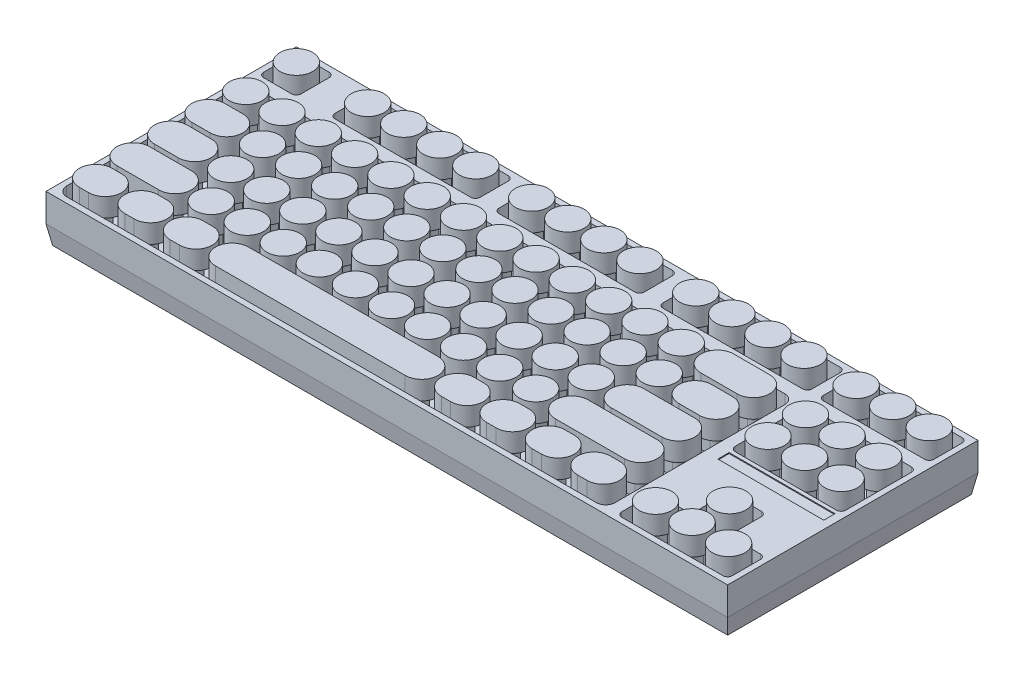
from build123d import *

# Parameters (mm, degrees)
SKETCH1_W            = 360
SKETCH1_H            = 130
BOSS_EXTRUDE1_DEPTH  = 10
DRAFT1_ANGLE         = 10
SKETCH2_W            = 363.526539614
SKETCH2_H            = 133.526539614
BOSS_EXTRUDE2_DEPTH  = 15
SKETCH3_R            = 4.5
BOSS_EXTRUDE3_DEPTH  = 15
BOSS_EXTRUDE5_START  = -4
SKETCH4_R            = 8.75
BOSS_EXTRUDE5_DEPTH  = 10
SKETCH5_W            = 56.5
SKETCH5_H            = 6
CUT_EXTRUDE1_DEPTH   = 0.5
SKETCH6_W            = 20
SKETCH6_H            = 20
CUT_EXTRUDE2_DEPTH   = 3
BOSS_EXTRUDE6_DEPTH  = 1
CUT_EXTRUDE3_DEPTH   = 20
CUT_EXTRUDE4_START   = -270
CUT_EXTRUDE4_DEPTH   = 20
BOSS_EXTRUDE7_DEPTH  = 20
BOSS_EXTRUDE8_START  = -290
BOSS_EXTRUDE8_DEPTH  = 20
BOSS_EXTRUDE12_DEPTH = 20
BOSS_EXTRUDE13_START = -290
BOSS_EXTRUDE13_DEPTH = 20


with BuildPart() as part:
    # Sketch1 → Boss-Extrude1 (new body)
    with BuildSketch(Plane(origin=(0, 0, 0), x_dir=(1, 0, 0), z_dir=(0, 1, 0))):
        Rectangle(SKETCH1_W, SKETCH1_H)
    extrude(amount=BOSS_EXTRUDE1_DEPTH)

    # Draft1
    draft1_faces = [part.faces().sort_by_distance(p)[0] for p in [
        (180, 5, 0),
        (0, 5, -65),
        (-180, 5, 0),
        (0, 5, 65),
    ]]
    draft(draft1_faces, Plane(origin=(0, 0, 0), x_dir=(0, 0, -1), z_dir=(0, -1, 0)), DRAFT1_ANGLE)

    # Sketch2 → Boss-Extrude2 (add)
    with BuildSketch(Plane(origin=(0, 10, 0), x_dir=(1, 0, 0), z_dir=(0, 1, 0))):
        Rectangle(SKETCH2_W, SKETCH2_H)
        with BuildLine():
            Line((111.263269807, 63.763269807), (36.766730193, 63.763269807))
            ThreePointArc((36.766730193, 63.763269807), (34.99896324, 63.03103676), (34.266730193, 61.263269807))
            Line((34.266730193, 61.263269807), (34.266730193, 46.263269807))
            ThreePointArc((34.266730193, 46.263269807), (34.99896324, 44.495502854), (36.766730193, 43.763269807))
            Line((36.766730193, 43.763269807), (111.263269807, 43.763269807))
            ThreePointArc((111.263269807, 43.763269807), (113.03103676, 44.495502854), (113.763269807, 46.263269807))
            Line((113.763269807, 46.263269807), (113.763269807, 61.263269807))
            ThreePointArc((113.763269807, 61.263269807), (113.03103676, 63.03103676), (111.263269807, 63.763269807))
        make_face(mode=Mode.SUBTRACT)
        with BuildLine():
            Line((176.263269807, 63.763269807), (122.263269807, 63.763269807))
            ThreePointArc((122.263269807, 63.763269807), (120.495502854, 63.03103676), (119.763269807, 61.263269807))
            Line((119.763269807, 61.263269807), (119.763269807, 46.263269807))
            ThreePointArc((119.763269807, 46.263269807), (120.495502854, 44.495502854), (122.263269807, 43.763269807))
            Line((122.263269807, 43.763269807), (176.263269807, 43.763269807))
            ThreePointArc((176.263269807, 43.763269807), (178.03103676, 44.495502854), (178.763269807, 46.263269807))
            Line((178.763269807, 46.263269807), (178.763269807, 61.263269807))
            ThreePointArc((178.763269807, 61.263269807), (178.03103676, 63.03103676), (176.263269807, 63.763269807))
        make_face(mode=Mode.SUBTRACT)
        with BuildLine():
            Line((178.763269807, -46.263269807), (178.763269807, -61.263269807))
            ThreePointArc((178.763269807, -61.263269807), (178.03103676, -63.03103676), (176.263269807, -63.763269807))
            Line((176.263269807, -63.763269807), (122.263269807, -63.763269807))
            ThreePointArc((122.263269807, -63.763269807), (120.495502854, -63.03103676), (119.763269807, -61.263269807))
            Line((119.763269807, -61.263269807), (119.763269807, -46.263269807))
            ThreePointArc((119.763269807, -46.263269807), (120.495502854, -44.495502854), (122.263269807, -43.763269807))
            Line((122.263269807, -43.763269807), (136.763269807, -43.763269807))
            ThreePointArc((136.763269807, -43.763269807), (138.53103676, -43.03103676), (139.263269807, -41.263269807))
            Line((139.263269807, -41.263269807), (139.263269807, -26.263269807))
            ThreePointArc((139.263269807, -26.263269807), (139.995502854, -24.495502854), (141.763269807, -23.763269807))
            Line((141.763269807, -23.763269807), (156.763269807, -23.763269807))
            ThreePointArc((156.763269807, -23.763269807), (158.53103676, -24.495502854), (159.263269807, -26.263269807))
            Line((159.263269807, -26.263269807), (159.263269807, -41.263269807))
            ThreePointArc((159.263269807, -41.263269807), (159.995502854, -43.03103676), (161.763269807, -43.763269807))
            Line((161.763269807, -43.763269807), (176.263269807, -43.763269807))
            ThreePointArc((176.263269807, -43.763269807), (178.03103676, -44.495502854), (178.763269807, -46.263269807))
        make_face(mode=Mode.SUBTRACT)
        with BuildLine():
            Line((-178.763269807, 31.763269807), (-178.763269807, -58.763269807))
            ThreePointArc((-178.763269807, -58.763269807), (-177.298803713, -62.298803713), (-173.763269807, -63.763269807))
            Line((-173.763269807, -63.763269807), (108.763269807, -63.763269807))
            ThreePointArc((108.763269807, -63.763269807), (112.298803713, -62.298803713), (113.763269807, -58.763269807))
            Line((113.763269807, -58.763269807), (113.763269807, 31.763269807))
            ThreePointArc((113.763269807, 31.763269807), (112.298803713, 35.298803713), (108.763269807, 36.763269807))
            Line((108.763269807, 36.763269807), (-173.763269807, 36.763269807))
            ThreePointArc((-173.763269807, 36.763269807), (-177.298803713, 35.298803713), (-178.763269807, 31.763269807))
        make_face(mode=Mode.SUBTRACT)
        with BuildLine():
            Line((-161.263269807, 63.763269807), (-176.263269807, 63.763269807))
            ThreePointArc((-176.263269807, 63.763269807), (-178.03103676, 63.03103676), (-178.763269807, 61.263269807))
            Line((-178.763269807, 61.263269807), (-178.763269807, 46.263269807))
            ThreePointArc((-178.763269807, 46.263269807), (-178.03103676, 44.495502854), (-176.263269807, 43.763269807))
            Line((-176.263269807, 43.763269807), (-161.263269807, 43.763269807))
            ThreePointArc((-161.263269807, 43.763269807), (-159.495502854, 44.495502854), (-158.763269807, 46.263269807))
            Line((-158.763269807, 46.263269807), (-158.763269807, 61.263269807))
            ThreePointArc((-158.763269807, 61.263269807), (-159.495502854, 63.03103676), (-161.263269807, 63.763269807))
        make_face(mode=Mode.SUBTRACT)
        with BuildLine():
            Line((-65.733269807, 63.763269807), (-138.233269807, 63.763269807))
            ThreePointArc((-138.233269807, 63.763269807), (-140.00103676, 63.03103676), (-140.733269807, 61.263269807))
            Line((-140.733269807, 61.263269807), (-140.733269807, 46.263269807))
            ThreePointArc((-140.733269807, 46.263269807), (-140.00103676, 44.495502854), (-138.233269807, 43.763269807))
            Line((-138.233269807, 43.763269807), (-65.733269807, 43.763269807))
            ThreePointArc((-65.733269807, 43.763269807), (-63.965502854, 44.495502854), (-63.233269807, 46.263269807))
            Line((-63.233269807, 46.263269807), (-63.233269807, 61.263269807))
            ThreePointArc((-63.233269807, 61.263269807), (-63.965502854, 63.03103676), (-65.733269807, 63.763269807))
        make_face(mode=Mode.SUBTRACT)
        with BuildLine():
            Line((21.766730193, 63.763269807), (-50.733269807, 63.763269807))
            ThreePointArc((-50.733269807, 63.763269807), (-52.50103676, 63.03103676), (-53.233269807, 61.263269807))
            Line((-53.233269807, 61.263269807), (-53.233269807, 46.263269807))
            ThreePointArc((-53.233269807, 46.263269807), (-52.50103676, 44.495502854), (-50.733269807, 43.763269807))
            Line((-50.733269807, 43.763269807), (21.766730193, 43.763269807))
            ThreePointArc((21.766730193, 43.763269807), (23.534497146, 44.495502854), (24.266730193, 46.263269807))
            Line((24.266730193, 46.263269807), (24.266730193, 61.263269807))
            ThreePointArc((24.266730193, 61.263269807), (23.534497146, 63.03103676), (21.766730193, 63.763269807))
        make_face(mode=Mode.SUBTRACT)
        with BuildLine():
            Line((176.263269807, 36.763269807), (122.263269807, 36.763269807))
            ThreePointArc((122.263269807, 36.763269807), (120.495502854, 36.03103676), (119.763269807, 34.263269807))
            Line((119.763269807, 34.263269807), (119.763269807, -0.736730193))
            ThreePointArc((119.763269807, -0.736730193), (120.495502854, -2.504497146), (122.263269807, -3.236730193))
            Line((122.263269807, -3.236730193), (176.263269807, -3.236730193))
            ThreePointArc((176.263269807, -3.236730193), (178.03103676, -2.504497146), (178.763269807, -0.736730193))
            Line((178.763269807, -0.736730193), (178.763269807, 34.263269807))
            ThreePointArc((178.763269807, 34.263269807), (178.03103676, 36.03103676), (176.263269807, 36.763269807))
        make_face(mode=Mode.SUBTRACT)
    extrude(amount=BOSS_EXTRUDE2_DEPTH)

    # Sketch3 → Boss-Extrude3 (add)
    with BuildSketch(Plane(origin=(0, 10, 0), x_dir=(1, 0, 0), z_dir=(0, 1, 0))):
        with Locations((-168.763269807, 53.763269807)):
            Circle(SKETCH3_R)
        with Locations((-130.733269807, 53.763269807)):
            Circle(SKETCH3_R)
        with Locations((-111.508269807, 53.763269807)):
            Circle(SKETCH3_R)
        with Locations((-92.458269807, 53.763269807)):
            Circle(SKETCH3_R)
        with Locations((-73.233269807, 53.763269807)):
            Circle(SKETCH3_R)
        with Locations((-43.233269807, 53.763269807)):
            Circle(SKETCH3_R)
        with Locations((44.266730193, 53.763269807)):
            Circle(SKETCH3_R)
        with Locations((129.763269807, 53.763269807)):
            Circle(SKETCH3_R)
        with Locations((-24.003269807, 53.763269807)):
            Circle(SKETCH3_R)
        with Locations((-4.773269807, 53.763269807)):
            Circle(SKETCH3_R)
        with Locations((14.456730193, 53.763269807)):
            Circle(SKETCH3_R)
        with Locations((63.496730193, 53.763269807)):
            Circle(SKETCH3_R)
        with Locations((82.726730193, 53.763269807)):
            Circle(SKETCH3_R)
        with Locations((101.956730193, 53.763269807)):
            Circle(SKETCH3_R)
        with Locations((168.763269807, 53.763269807)):
            Circle(SKETCH3_R)
        with Locations((149.263269807, 53.763269807)):
            Circle(SKETCH3_R)
        with Locations((129.763269807, 26.763269807)):
            Circle(SKETCH3_R)
        with Locations((149.263269807, 26.763269807)):
            Circle(SKETCH3_R)
        with Locations((168.763269807, 26.763269807)):
            Circle(SKETCH3_R)
        with Locations((168.763269807, 6.763269807)):
            Circle(SKETCH3_R)
        with Locations((149.263269807, 6.763269807)):
            Circle(SKETCH3_R)
        with Locations((129.763269807, 6.763269807)):
            Circle(SKETCH3_R)
        with Locations((63.496730193, 26.763269807)):
            Circle(SKETCH3_R)
        with Locations((44.141730193, 26.763269807)):
            Circle(SKETCH3_R)
        with Locations((24.786730193, 26.763269807)):
            Circle(SKETCH3_R)
        with Locations((5.431730193, 26.763269807)):
            Circle(SKETCH3_R)
        with Locations((-13.923269807, 26.763269807)):
            Circle(SKETCH3_R)
        with Locations((-33.278269807, 26.763269807)):
            Circle(SKETCH3_R)
        with Locations((-52.633269807, 26.763269807)):
            Circle(SKETCH3_R)
        with Locations((-71.988269807, 26.763269807)):
            Circle(SKETCH3_R)
        with Locations((-91.343269807, 26.763269807)):
            Circle(SKETCH3_R)
        with Locations((-110.698269807, 26.763269807)):
            Circle(SKETCH3_R)
        with Locations((-130.053269807, 26.763269807)):
            Circle(SKETCH3_R)
        with Locations((-149.408269807, 26.763269807)):
            Circle(SKETCH3_R)
        with Locations((-168.763269807, 26.763269807)):
            Circle(SKETCH3_R)
        with Locations((129.763269807, -53.236730193)):
            Circle(SKETCH3_R)
        with Locations((149.263269807, -53.236730193)):
            Circle(SKETCH3_R)
        with Locations((168.763269807, -53.236730193)):
            Circle(SKETCH3_R)
        with Locations((149.263269807, -33.236730193)):
            Circle(SKETCH3_R)
        with Locations((-139.793269807, 6.763269807)):
            Circle(SKETCH3_R)
        with Locations((-120.563269807, 6.763269807)):
            Circle(SKETCH3_R)
        with Locations((-101.333269807, 6.763269807)):
            Circle(SKETCH3_R)
        with Locations((-82.103269807, 6.763269807)):
            Circle(SKETCH3_R)
        with Locations((-62.873269807, 6.763269807)):
            Circle(SKETCH3_R)
        with Locations((-43.643269807, 6.763269807)):
            Circle(SKETCH3_R)
        with Locations((-24.413269807, 6.763269807)):
            Circle(SKETCH3_R)
        with Locations((-5.183269807, 6.763269807)):
            Circle(SKETCH3_R)
        with Locations((14.046730193, 6.763269807)):
            Circle(SKETCH3_R)
        with Locations((33.276730193, 6.763269807)):
            Circle(SKETCH3_R)
        with Locations((52.506730193, 6.763269807)):
            Circle(SKETCH3_R)
        with Locations((71.736730193, 6.763269807)):
            Circle(SKETCH3_R)
        with Locations((-136.793269807, -13.236730193)):
            Circle(SKETCH3_R)
        with Locations((-117.563269807, -13.236730193)):
            Circle(SKETCH3_R)
        with Locations((-98.333269807, -13.236730193)):
            Circle(SKETCH3_R)
        with Locations((-79.103269807, -13.236730193)):
            Circle(SKETCH3_R)
        with Locations((-59.873269807, -13.236730193)):
            Circle(SKETCH3_R)
        with Locations((-40.643269807, -13.236730193)):
            Circle(SKETCH3_R)
        with Locations((-21.413269807, -13.236730193)):
            Circle(SKETCH3_R)
        with Locations((-2.183269807, -13.236730193)):
            Circle(SKETCH3_R)
        with Locations((17.046730193, -13.236730193)):
            Circle(SKETCH3_R)
        with Locations((36.276730193, -13.236730193)):
            Circle(SKETCH3_R)
        with Locations((55.506730193, -13.236730193)):
            Circle(SKETCH3_R)
        with Locations((-127.178269807, -33.236730193)):
            Circle(SKETCH3_R)
        with Locations((-107.948269807, -33.236730193)):
            Circle(SKETCH3_R)
        with Locations((-88.718269807, -33.236730193)):
            Circle(SKETCH3_R)
        with Locations((-69.488269807, -33.236730193)):
            Circle(SKETCH3_R)
        with Locations((-50.258269807, -33.236730193)):
            Circle(SKETCH3_R)
        with Locations((-31.028269807, -33.236730193)):
            Circle(SKETCH3_R)
        with Locations((-11.798269807, -33.236730193)):
            Circle(SKETCH3_R)
        with Locations((7.431730193, -33.236730193)):
            Circle(SKETCH3_R)
        with Locations((26.661730193, -33.236730193)):
            Circle(SKETCH3_R)
        with Locations((45.891730193, -33.236730193)):
            Circle(SKETCH3_R)
        with BuildLine():
            Line((-168.763269807, 9.763269807), (-159.023269807, 9.763269807))
            ThreePointArc((-159.023269807, 9.763269807), (-156.023269807, 6.763269807), (-159.023269807, 3.763269807))
            Line((-159.023269807, 3.763269807), (-168.763269807, 3.763269807))
            ThreePointArc((-168.763269807, 3.763269807), (-171.763269807, 6.763269807), (-168.763269807, 9.763269807))
        make_face()
        with BuildLine():
            Line((-168.763269807, -10.236730193), (-156.023269807, -10.236730193))
            ThreePointArc((-156.023269807, -10.236730193), (-153.023269807, -13.236730193), (-156.023269807, -16.236730193))
            Line((-156.023269807, -16.236730193), (-168.763269807, -16.236730193))
            ThreePointArc((-168.763269807, -16.236730193), (-171.763269807, -13.236730193), (-168.763269807, -10.236730193))
        make_face()
        with BuildLine():
            Line((-168.763269807, -30.236730193), (-146.408269807, -30.236730193))
            ThreePointArc((-146.408269807, -30.236730193), (-143.408269807, -33.236730193), (-146.408269807, -36.236730193))
            Line((-146.408269807, -36.236730193), (-168.763269807, -36.236730193))
            ThreePointArc((-168.763269807, -36.236730193), (-171.763269807, -33.236730193), (-168.763269807, -30.236730193))
        make_face()
        with BuildLine():
            Line((82.726730193, 29.763269807), (101.956730193, 29.763269807))
            ThreePointArc((101.956730193, 29.763269807), (104.956730193, 26.763269807), (101.956730193, 23.763269807))
            Line((101.956730193, 23.763269807), (82.726730193, 23.763269807))
            ThreePointArc((82.726730193, 23.763269807), (79.726730193, 26.763269807), (82.726730193, 29.763269807))
        make_face()
        with BuildLine():
            Line((90.966730193, 9.763269807), (101.956730193, 9.763269807))
            ThreePointArc((101.956730193, 9.763269807), (104.956730193, 6.763269807), (101.956730193, 3.763269807))
            Line((101.956730193, 3.763269807), (90.966730193, 3.763269807))
            ThreePointArc((90.966730193, 3.763269807), (87.966730193, 6.763269807), (90.966730193, 9.763269807))
        make_face()
        with BuildLine():
            Line((74.736730193, -10.236730193), (101.956730193, -10.236730193))
            ThreePointArc((101.956730193, -10.236730193), (104.956730193, -13.236730193), (101.956730193, -16.236730193))
            Line((101.956730193, -16.236730193), (74.736730193, -16.236730193))
            ThreePointArc((74.736730193, -16.236730193), (71.736730193, -13.236730193), (74.736730193, -10.236730193))
        make_face()
        with BuildLine():
            Line((65.121730193, -30.236730193), (101.956730193, -30.236730193))
            ThreePointArc((101.956730193, -30.236730193), (104.956730193, -33.236730193), (101.956730193, -36.236730193))
            Line((101.956730193, -36.236730193), (65.121730193, -36.236730193))
            ThreePointArc((65.121730193, -36.236730193), (62.121730193, -33.236730193), (65.121730193, -30.236730193))
        make_face()
        with BuildLine():
            Line((-168.763269807, -50.236730193), (-163.763269807, -50.236730193))
            ThreePointArc((-163.763269807, -50.236730193), (-160.763269807, -53.236730193), (-163.763269807, -56.236730193))
            Line((-163.763269807, -56.236730193), (-168.763269807, -56.236730193))
            ThreePointArc((-168.763269807, -56.236730193), (-171.763269807, -53.236730193), (-168.763269807, -50.236730193))
        make_face()
        with BuildLine():
            Line((-144.533269807, -50.236730193), (-139.533269807, -50.236730193))
            ThreePointArc((-139.533269807, -50.236730193), (-136.533269807, -53.236730193), (-139.533269807, -56.236730193))
            Line((-139.533269807, -56.236730193), (-144.533269807, -56.236730193))
            ThreePointArc((-144.533269807, -56.236730193), (-147.533269807, -53.236730193), (-144.533269807, -50.236730193))
        make_face()
        with BuildLine():
            Line((-120.303269807, -50.236730193), (-115.303269807, -50.236730193))
            ThreePointArc((-115.303269807, -50.236730193), (-112.303269807, -53.236730193), (-115.303269807, -56.236730193))
            Line((-115.303269807, -56.236730193), (-120.303269807, -56.236730193))
            ThreePointArc((-120.303269807, -56.236730193), (-123.303269807, -53.236730193), (-120.303269807, -50.236730193))
        make_face()
        with BuildLine():
            Line((96.956730193, -50.236730193), (101.956730193, -50.236730193))
            ThreePointArc((101.956730193, -50.236730193), (104.956730193, -53.236730193), (101.956730193, -56.236730193))
            Line((101.956730193, -56.236730193), (96.956730193, -56.236730193))
            ThreePointArc((96.956730193, -56.236730193), (93.956730193, -53.236730193), (96.956730193, -50.236730193))
        make_face()
        with BuildLine():
            Line((72.726730193, -50.236730193), (77.726730193, -50.236730193))
            ThreePointArc((77.726730193, -50.236730193), (80.726730193, -53.236730193), (77.726730193, -56.236730193))
            Line((77.726730193, -56.236730193), (72.726730193, -56.236730193))
            ThreePointArc((72.726730193, -56.236730193), (69.726730193, -53.236730193), (72.726730193, -50.236730193))
        make_face()
        with BuildLine():
            Line((48.496730193, -50.236730193), (53.496730193, -50.236730193))
            ThreePointArc((53.496730193, -50.236730193), (56.496730193, -53.236730193), (53.496730193, -56.236730193))
            Line((53.496730193, -56.236730193), (48.496730193, -56.236730193))
            ThreePointArc((48.496730193, -56.236730193), (45.496730193, -53.236730193), (48.496730193, -50.236730193))
        make_face()
        with BuildLine():
            Line((24.266730193, -50.236730193), (29.266730193, -50.236730193))
            ThreePointArc((29.266730193, -50.236730193), (32.266730193, -53.236730193), (29.266730193, -56.236730193))
            Line((29.266730193, -56.236730193), (24.266730193, -56.236730193))
            ThreePointArc((24.266730193, -56.236730193), (21.266730193, -53.236730193), (24.266730193, -50.236730193))
        make_face()
        with BuildLine():
            Line((-96.073269807, -50.236730193), (5.036730193, -50.236730193))
            ThreePointArc((5.036730193, -50.236730193), (8.036730193, -53.236730193), (5.036730193, -56.236730193))
            Line((5.036730193, -56.236730193), (-96.073269807, -56.236730193))
            ThreePointArc((-96.073269807, -56.236730193), (-99.073269807, -53.236730193), (-96.073269807, -50.236730193))
        make_face()
    extrude(amount=BOSS_EXTRUDE3_DEPTH)

    # Sketch4 → Boss-Extrude5 (add)
    with BuildSketch(Plane(origin=(0, 25, 0), x_dir=(1, 0, 0), z_dir=(0, 1, 0)).offset(BOSS_EXTRUDE5_START)):
        with Locations((-168.763269807, 53.763269807)):
            Circle(SKETCH4_R)
        with Locations((-130.733269807, 53.763269807)):
            Circle(SKETCH4_R)
        with Locations((-111.508269807, 53.763269807)):
            Circle(SKETCH4_R)
        with Locations((-92.283269807, 53.763269807)):
            Circle(SKETCH4_R)
        with Locations((-73.058269807, 53.763269807)):
            Circle(SKETCH4_R)
        with Locations((-43.233269807, 53.763269807)):
            Circle(SKETCH4_R)
        with Locations((-24.003269807, 53.763269807)):
            Circle(SKETCH4_R)
        with Locations((-4.773269807, 53.763269807)):
            Circle(SKETCH4_R)
        with Locations((14.456730193, 53.763269807)):
            Circle(SKETCH4_R)
        with Locations((44.266730193, 53.763269807)):
            Circle(SKETCH4_R)
        with Locations((63.496730193, 53.763269807)):
            Circle(SKETCH4_R)
        with Locations((82.726730193, 53.763269807)):
            Circle(SKETCH4_R)
        with Locations((101.956730193, 53.763269807)):
            Circle(SKETCH4_R)
        with Locations((129.763269807, 53.763269807)):
            Circle(SKETCH4_R)
        with Locations((149.263269807, 53.763269807)):
            Circle(SKETCH4_R)
        with Locations((168.763269807, 53.763269807)):
            Circle(SKETCH4_R)
        with Locations((63.496730193, 26.763269807)):
            Circle(SKETCH4_R)
        with Locations((44.141730193, 26.763269807)):
            Circle(SKETCH4_R)
        with Locations((24.786730193, 26.763269807)):
            Circle(SKETCH4_R)
        with Locations((5.431730193, 26.763269807)):
            Circle(SKETCH4_R)
        with Locations((-13.923269807, 26.763269807)):
            Circle(SKETCH4_R)
        with Locations((-33.278269807, 26.763269807)):
            Circle(SKETCH4_R)
        with Locations((-52.633269807, 26.763269807)):
            Circle(SKETCH4_R)
        with Locations((-71.988269807, 26.763269807)):
            Circle(SKETCH4_R)
        with Locations((-91.343269807, 26.763269807)):
            Circle(SKETCH4_R)
        with Locations((-110.698269807, 26.763269807)):
            Circle(SKETCH4_R)
        with Locations((-130.053269807, 26.763269807)):
            Circle(SKETCH4_R)
        with Locations((-149.408269807, 26.763269807)):
            Circle(SKETCH4_R)
        with Locations((-168.763269807, 26.763269807)):
            Circle(SKETCH4_R)
        with Locations((71.736730193, 6.763269807)):
            Circle(SKETCH4_R)
        with Locations((52.506730193, 6.763269807)):
            Circle(SKETCH4_R)
        with Locations((33.276730193, 6.763269807)):
            Circle(SKETCH4_R)
        with Locations((14.046730193, 6.763269807)):
            Circle(SKETCH4_R)
        with Locations((-5.183269807, 6.763269807)):
            Circle(SKETCH4_R)
        with Locations((-24.413269807, 6.763269807)):
            Circle(SKETCH4_R)
        with Locations((-43.643269807, 6.763269807)):
            Circle(SKETCH4_R)
        with Locations((-62.873269807, 6.763269807)):
            Circle(SKETCH4_R)
        with Locations((-82.103269807, 6.763269807)):
            Circle(SKETCH4_R)
        with Locations((-101.333269807, 6.763269807)):
            Circle(SKETCH4_R)
        with Locations((-120.563269807, 6.763269807)):
            Circle(SKETCH4_R)
        with Locations((-139.793269807, 6.763269807)):
            Circle(SKETCH4_R)
        with Locations((129.763269807, 26.763269807)):
            Circle(SKETCH4_R)
        with Locations((129.763269807, 6.763269807)):
            Circle(SKETCH4_R)
        with Locations((168.763269807, 26.763269807)):
            Circle(SKETCH4_R)
        with Locations((168.763269807, 6.763269807)):
            Circle(SKETCH4_R)
        with Locations((149.263269807, 26.763269807)):
            Circle(SKETCH4_R)
        with Locations((149.263269807, 6.763269807)):
            Circle(SKETCH4_R)
        with Locations((129.763269807, -53.236730193)):
            Circle(SKETCH4_R)
        with Locations((149.263269807, -33.236730193)):
            Circle(SKETCH4_R)
        with Locations((149.263269807, -53.236730193)):
            Circle(SKETCH4_R)
        with Locations((168.763269807, -53.236730193)):
            Circle(SKETCH4_R)
        with Locations((-136.793269807, -13.236730193)):
            Circle(SKETCH4_R)
        with Locations((-117.563269807, -13.236730193)):
            Circle(SKETCH4_R)
        with Locations((-98.333269807, -13.236730193)):
            Circle(SKETCH4_R)
        with Locations((-79.103269807, -13.236730193)):
            Circle(SKETCH4_R)
        with Locations((-59.873269807, -13.236730193)):
            Circle(SKETCH4_R)
        with Locations((-40.643269807, -13.236730193)):
            Circle(SKETCH4_R)
        with Locations((-21.413269807, -13.236730193)):
            Circle(SKETCH4_R)
        with Locations((-2.183269807, -13.236730193)):
            Circle(SKETCH4_R)
        with Locations((17.046730193, -13.236730193)):
            Circle(SKETCH4_R)
        with Locations((36.276730193, -13.236730193)):
            Circle(SKETCH4_R)
        with Locations((55.506730193, -13.236730193)):
            Circle(SKETCH4_R)
        with Locations((-127.178269807, -33.236730193)):
            Circle(SKETCH4_R)
        with Locations((-107.948269807, -33.236730193)):
            Circle(SKETCH4_R)
        with Locations((-88.718269807, -33.236730193)):
            Circle(SKETCH4_R)
        with Locations((-69.488269807, -33.236730193)):
            Circle(SKETCH4_R)
        with Locations((-50.258269807, -33.236730193)):
            Circle(SKETCH4_R)
        with Locations((-31.028269807, -33.236730193)):
            Circle(SKETCH4_R)
        with Locations((-11.798269807, -33.236730193)):
            Circle(SKETCH4_R)
        with Locations((7.431730193, -33.236730193)):
            Circle(SKETCH4_R)
        with Locations((26.661730193, -33.236730193)):
            Circle(SKETCH4_R)
        with Locations((45.891730193, -33.236730193)):
            Circle(SKETCH4_R)
        with BuildLine():
            Line((-168.763269807, 15.513269807), (-159.023269807, 15.513269807))
            ThreePointArc((-159.023269807, 15.513269807), (-150.273269807, 6.763269807), (-159.023269807, -1.986730193))
            Line((-159.023269807, -1.986730193), (-168.763269807, -1.986730193))
            ThreePointArc((-168.763269807, -1.986730193), (-177.513269807, 6.763269807), (-168.763269807, 15.513269807))
        make_face()
        with BuildLine():
            Line((-168.763269807, -4.486730193), (-156.023269807, -4.486730193))
            ThreePointArc((-156.023269807, -4.486730193), (-147.273269807, -13.236730193), (-156.023269807, -21.986730193))
            Line((-156.023269807, -21.986730193), (-168.763269807, -21.986730193))
            ThreePointArc((-168.763269807, -21.986730193), (-177.513269807, -13.236730193), (-168.763269807, -4.486730193))
        make_face()
        with BuildLine():
            Line((-168.763269807, -24.486730193), (-146.408269807, -24.486730193))
            ThreePointArc((-146.408269807, -24.486730193), (-137.658269807, -33.236730193), (-146.408269807, -41.986730193))
            Line((-146.408269807, -41.986730193), (-168.763269807, -41.986730193))
            ThreePointArc((-168.763269807, -41.986730193), (-177.513269807, -33.236730193), (-168.763269807, -24.486730193))
        make_face()
        with BuildLine():
            Line((82.726730193, 35.513269807), (101.956730193, 35.513269807))
            ThreePointArc((101.956730193, 35.513269807), (110.706730193, 26.763269807), (101.956730193, 18.013269807))
            Line((101.956730193, 18.013269807), (82.726730193, 18.013269807))
            ThreePointArc((82.726730193, 18.013269807), (73.976730193, 26.763269807), (82.726730193, 35.513269807))
        make_face()
        with BuildLine():
            Line((90.966730193, 15.513269807), (101.956730193, 15.513269807))
            ThreePointArc((101.956730193, 15.513269807), (110.706730193, 6.763269807), (101.956730193, -1.986730193))
            Line((101.956730193, -1.986730193), (90.966730193, -1.986730193))
            ThreePointArc((90.966730193, -1.986730193), (82.216730193, 6.763269807), (90.966730193, 15.513269807))
        make_face()
        with BuildLine():
            Line((74.736730193, -4.486730193), (101.956730193, -4.486730193))
            ThreePointArc((101.956730193, -4.486730193), (110.706730193, -13.236730193), (101.956730193, -21.986730193))
            Line((101.956730193, -21.986730193), (74.736730193, -21.986730193))
            ThreePointArc((74.736730193, -21.986730193), (65.986730193, -13.236730193), (74.736730193, -4.486730193))
        make_face()
        with BuildLine():
            Line((65.121730193, -24.486730193), (101.956730193, -24.486730193))
            ThreePointArc((101.956730193, -24.486730193), (110.706730193, -33.236730193), (101.956730193, -41.986730193))
            Line((101.956730193, -41.986730193), (65.121730193, -41.986730193))
            ThreePointArc((65.121730193, -41.986730193), (56.371730193, -33.236730193), (65.121730193, -24.486730193))
        make_face()
        with BuildLine():
            Line((-168.763269807, -44.486730193), (-163.763269807, -44.486730193))
            ThreePointArc((-163.763269807, -44.486730193), (-155.013269807, -53.236730193), (-163.763269807, -61.986730193))
            Line((-163.763269807, -61.986730193), (-168.763269807, -61.986730193))
            ThreePointArc((-168.763269807, -61.986730193), (-177.513269807, -53.236730193), (-168.763269807, -44.486730193))
        make_face()
        with BuildLine():
            Line((-144.533269807, -61.986730193), (-139.533269807, -61.986730193))
            ThreePointArc((-139.533269807, -61.986730193), (-130.783269807, -53.236730193), (-139.533269807, -44.486730193))
            Line((-139.533269807, -44.486730193), (-144.533269807, -44.486730193))
            ThreePointArc((-144.533269807, -44.486730193), (-153.283269807, -53.236730193), (-144.533269807, -61.986730193))
        make_face()
        with BuildLine():
            Line((-120.303269807, -61.986730193), (-115.303269807, -61.986730193))
            ThreePointArc((-115.303269807, -61.986730193), (-106.553269807, -53.236730193), (-115.303269807, -44.486730193))
            Line((-115.303269807, -44.486730193), (-120.303269807, -44.486730193))
            ThreePointArc((-120.303269807, -44.486730193), (-129.053269807, -53.236730193), (-120.303269807, -61.986730193))
        make_face()
        with BuildLine():
            Line((96.956730193, -61.986730193), (101.956730193, -61.986730193))
            ThreePointArc((101.956730193, -61.986730193), (110.706730193, -53.236730193), (101.956730193, -44.486730193))
            Line((101.956730193, -44.486730193), (96.956730193, -44.486730193))
            ThreePointArc((96.956730193, -44.486730193), (88.206730193, -53.236730193), (96.956730193, -61.986730193))
        make_face()
        with BuildLine():
            Line((72.726730193, -44.486730193), (77.726730193, -44.486730193))
            ThreePointArc((77.726730193, -44.486730193), (86.476730193, -53.236730193), (77.726730193, -61.986730193))
            Line((77.726730193, -61.986730193), (72.726730193, -61.986730193))
            ThreePointArc((72.726730193, -61.986730193), (63.976730193, -53.236730193), (72.726730193, -44.486730193))
        make_face()
        with BuildLine():
            Line((48.496730193, -44.486730193), (53.496730193, -44.486730193))
            ThreePointArc((53.496730193, -44.486730193), (62.246730193, -53.236730193), (53.496730193, -61.986730193))
            Line((53.496730193, -61.986730193), (48.496730193, -61.986730193))
            ThreePointArc((48.496730193, -61.986730193), (39.746730193, -53.236730193), (48.496730193, -44.486730193))
        make_face()
        with BuildLine():
            Line((24.266730193, -44.486730193), (29.266730193, -44.486730193))
            ThreePointArc((29.266730193, -44.486730193), (38.016730193, -53.236730193), (29.266730193, -61.986730193))
            Line((29.266730193, -61.986730193), (24.266730193, -61.986730193))
            ThreePointArc((24.266730193, -61.986730193), (15.516730193, -53.236730193), (24.266730193, -44.486730193))
        make_face()
        with BuildLine():
            Line((-96.073269807, -44.486730193), (5.036730193, -44.486730193))
            ThreePointArc((5.036730193, -44.486730193), (13.786730193, -53.236730193), (5.036730193, -61.986730193))
            Line((5.036730193, -61.986730193), (-96.073269807, -61.986730193))
            ThreePointArc((-96.073269807, -61.986730193), (-104.823269807, -53.236730193), (-96.073269807, -44.486730193))
        make_face()
    extrude(amount=BOSS_EXTRUDE5_DEPTH)

    # Sketch5 → Cut-Extrude1 (cut)
    with BuildSketch(Plane(origin=(0, 25, 0), x_dir=(1, 0, 0), z_dir=(0, 1, 0))):
        with Locations((149.263269807, -8.236730193)):
            Rectangle(SKETCH5_W, SKETCH5_H)
    extrude(amount=-CUT_EXTRUDE1_DEPTH, mode=Mode.SUBTRACT)

    # Sketch6 → Cut-Extrude2 (cut)
    with BuildSketch(Plane.XZ):
        with Locations((145, -25)):
            Rectangle(SKETCH6_W, SKETCH6_H)
        with Locations((-145, -25)):
            Rectangle(SKETCH6_W, SKETCH6_H)
    extrude(amount=-CUT_EXTRUDE2_DEPTH, mode=Mode.SUBTRACT)

    # Sketch7 → Boss-Extrude6 (add)
    with BuildSketch(Plane.XZ):
        with BuildLine():
            Line((-152, 58), (-138, 58))
            ThreePointArc((-138, 58), (-135, 55), (-138, 52))
            Line((-138, 52), (-152, 52))
            ThreePointArc((-152, 52), (-155, 55), (-152, 58))
        make_face()
        with BuildLine():
            Line((152, 58), (138, 58))
            ThreePointArc((138, 58), (135, 55), (138, 52))
            Line((138, 52), (152, 52))
            ThreePointArc((152, 52), (155, 55), (152, 58))
        make_face()
    extrude(amount=BOSS_EXTRUDE6_DEPTH)

    # Sketch8 → Cut-Extrude3 (cut)
    with BuildSketch(Plane(origin=(135, 0, 0), x_dir=(0, 0, -1), z_dir=(1, 0, 0))):
        with BuildLine():
            Line((35, 3), (44.171805683, -0.154817715))
            ThreePointArc((44.171805683, -0.154817715), (44.502329179, -0.710073922), (44.009173158, -1.127629159))
            Line((44.009173158, -1.127629159), (35, -1.127629159))
            Line((35, -1.127629159), (35, 3))
        make_face()
    extrude(amount=CUT_EXTRUDE3_DEPTH, mode=Mode.SUBTRACT)

    # Sketch8_2 → Cut-Extrude4 (cut)
    with BuildSketch(Plane(origin=(135, 0, 0), x_dir=(0, 0, -1), z_dir=(1, 0, 0)).offset(CUT_EXTRUDE4_START)):
        with BuildLine():
            Line((35, 3), (44.171805683, -0.154817715))
            ThreePointArc((44.171805683, -0.154817715), (44.502329179, -0.710073922), (44.009173158, -1.127629159))
            Line((44.009173158, -1.127629159), (35, -1.127629159))
            Line((35, -1.127629159), (35, 3))
        make_face()
    extrude(amount=-CUT_EXTRUDE4_DEPTH, mode=Mode.SUBTRACT)

    # Sketch9 → Boss-Extrude7 (add)
    with BuildSketch(Plane(origin=(135, 0, 0), x_dir=(0, 0, -1), z_dir=(1, 0, 0))):
        with BuildLine():
            Line((43.721713752, 0), (45.033224709, 0))
            ThreePointArc((45.033224709, 0), (44.377469231, -0.455082152), (43.721713752, 0))
        make_face()
    extrude(amount=BOSS_EXTRUDE7_DEPTH)

    # Sketch9_2 → Boss-Extrude8 (add)
    with BuildSketch(Plane(origin=(135, 0, 0), x_dir=(0, 0, -1), z_dir=(1, 0, 0)).offset(BOSS_EXTRUDE8_START)):
        with BuildLine():
            Line((43.721713752, 0), (45.033224709, 0))
            ThreePointArc((45.033224709, 0), (44.377469231, -0.455082152), (43.721713752, 0))
        make_face()
    extrude(amount=BOSS_EXTRUDE8_DEPTH)


with BuildPart() as body_2:
    # Sketch10 → Boss-Extrude12 (new body)
    with BuildSketch(Plane(origin=(135, 0, 0), x_dir=(0, 0, -1), z_dir=(1, 0, 0))):
        Polygon((40.23203472, 0.693231133), (54.549061213, -3.36806906), (54.549061213, -3.548922679), (54.549061213, -3.759351029), (53.292557818, -3.72644833), (40.23203472, 0), align=None)
    extrude(amount=BOSS_EXTRUDE12_DEPTH)


with BuildPart() as body_3:
    # Sketch10_3 → Boss-Extrude13 (new body)
    with BuildSketch(Plane(origin=(135, 0, 0), x_dir=(0, 0, -1), z_dir=(1, 0, 0)).offset(BOSS_EXTRUDE13_START)):
        Polygon((40.23203472, 0.693231133), (54.549061213, -3.36806906), (54.549061213, -3.548922679), (54.549061213, -3.759351029), (53.292557818, -3.72644833), (40.23203472, 0), align=None)
    extrude(amount=BOSS_EXTRUDE13_DEPTH)


solid = Compound([part.part, body_2.part, body_3.part])
